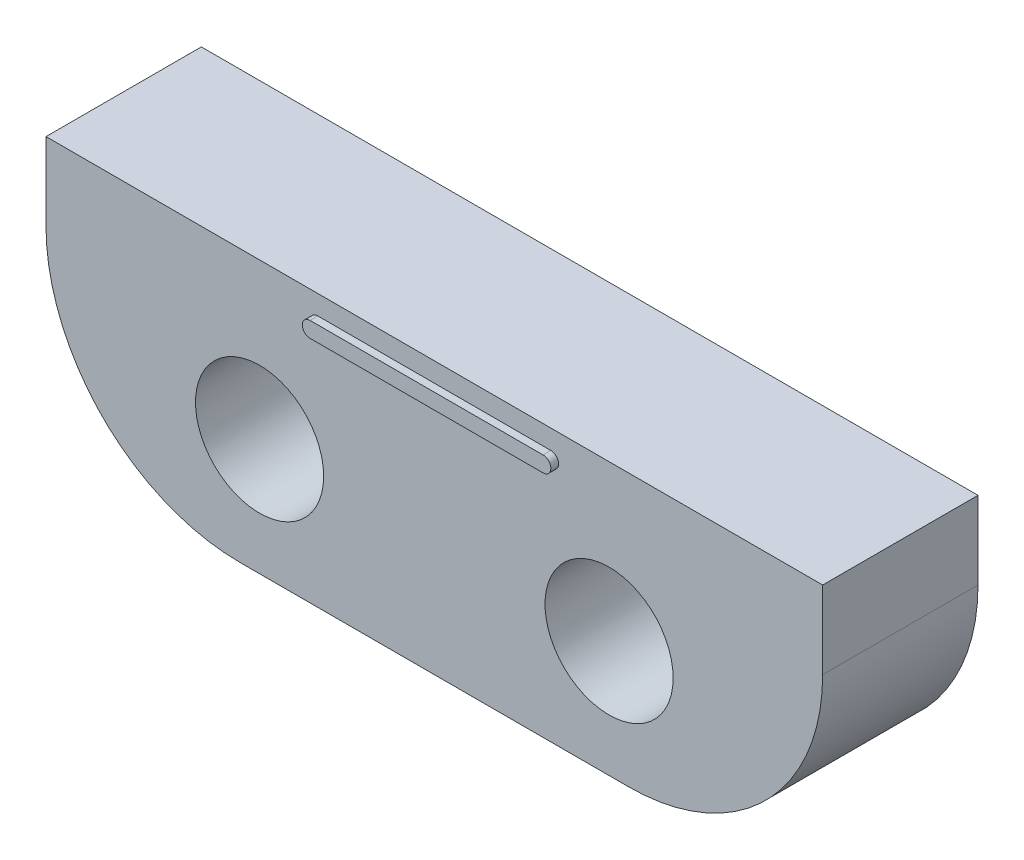
from build123d import *

# Parameters (mm, degrees)
SKETCH1_W           = 20
SKETCH1_H           = 7
SKETCH1_R           = 1.65
BOSS_EXTRUDE1_DEPTH = 4
BOSS_EXTRUDE2_DEPTH = 0.2
FILLET1_R           = 5


with BuildPart() as part:
    # Sketch1 → Boss-Extrude1 (new body)
    with BuildSketch(Plane.XY):
        with Locations((0, 0.5)):
            Rectangle(SKETCH1_W, SKETCH1_H)
        with Locations((-4.5, 0)):
            Circle(SKETCH1_R, mode=Mode.SUBTRACT)
        with Locations((4.5, 0)):
            Circle(SKETCH1_R, mode=Mode.SUBTRACT)
    extrude(amount=BOSS_EXTRUDE1_DEPTH)

    # Sketch2 → Boss-Extrude2 (add)
    with BuildSketch(Plane.XY.offset(4)):
        with BuildLine():
            Line((-3, 3.5), (3, 3.5))
            ThreePointArc((3, 3.5), (3.2, 3.3), (3, 3.1))
            Line((3, 3.1), (-3, 3.1))
            ThreePointArc((-3, 3.1), (-3.2, 3.3), (-3, 3.5))
        make_face()
    extrude(amount=BOSS_EXTRUDE2_DEPTH)

    # Fillet1
    fillet1_edges = [part.edges().sort_by_distance(p)[0] for p in [
        (10, -3, 2),
        (-10, -3, 2),
    ]]
    fillet(fillet1_edges, radius=FILLET1_R)


solid = part.part
